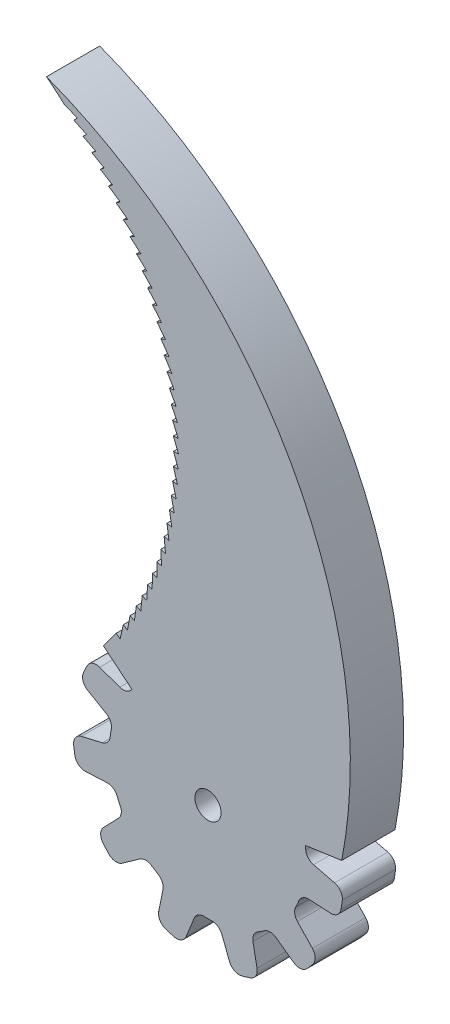
from build123d import *

# Parameters (mm, degrees)
ESBO_O1_R                = 1.6
RESSALTO_EXTRUS_O1_DEPTH = 6.5
RESSALTO_EXTRUS_O2_DEPTH = 6.5


with BuildPart() as part:
    # Esboço1 → Ressalto-extrusão1 (new body)
    with BuildSketch(Plane.XY):
        with BuildLine():
            Line((-1.729176319, 15.36379433), (-1.986939392, 12.728346928))
            ThreePointArc((-1.986939392, 12.728346928), (-2.28384954, 12.034303522), (-2.926191547, 11.637757646))
            ThreePointArc((-2.926191547, 11.637757646), (-3.379862838, 11.514188082), (-3.828344934, 11.372940476))
            ThreePointArc((-3.828344934, 11.372940476), (-4.589454473, 11.361285032), (-5.216203153, 11.793268448))
            Line((-5.216203153, 11.793268448), (-6.817074415, 13.864793941))
            ThreePointArc((-6.817074415, 13.864793941), (-7.572843667, 14.328475505), (-8.446001713, 14.174258833))
            ThreePointArc((-8.446001713, 14.174258833), (-8.906558945, 13.889484013), (-9.357523739, 13.589750104))
            ThreePointArc((-9.357523739, 13.589750104), (-9.86066415, 12.865881142), (-9.760970014, 11.989982959))
            Line((-9.760970014, 11.989982959), (-8.552983671, 9.633546283))
            ThreePointArc((-8.552983671, 9.633546283), (-8.427532188, 8.889158071), (-8.753515784, 8.208286144))
            ThreePointArc((-8.753515784, 8.208286144), (-9.06836161, 7.859059595), (-9.369284537, 7.497766819))
            ThreePointArc((-9.369284537, 7.497766819), (-10.003269217, 7.076474753), (-10.764071625, 7.101036409))
            Line((-10.764071625, 7.101036409), (-13.230761465, 7.9782182))
            ThreePointArc((-13.230761465, 7.9782182), (-14.117240198, 7.959692248), (-14.768411661, 7.357892048))
            ThreePointArc((-14.768411661, 7.357892048), (-15.001896169, 6.869328187), (-15.219223509, 6.373366001))
            ThreePointArc((-15.219223509, 6.373366001), (-15.25113905, 5.492390437), (-14.693724696, 4.809436716))
            Line((-14.693724696, 4.809436716), (-12.403516067, 3.480162761))
            ThreePointArc((-12.403516067, 3.480162761), (-11.895532912, 2.92176774), (-11.801660609, 2.172741789))
            ThreePointArc((-11.801660609, 2.172741789), (-11.877719645, 1.708735215), (-11.935542499, 1.242105174))
            ThreePointArc((-11.935542499, 1.242105174), (-12.241116663, 0.544933739), (-12.894423411, 0.154275483))
            Line((-12.894423411, 0.154275483), (-15.443775235, -0.441385447))
            ThreePointArc((-15.443775235, -0.441385447), (-16.179512714, -0.936237057), (-16.401955256, -1.794553473))
            ThreePointArc((-16.401955256, -1.794553473), (-16.334237357, -2.331790803), (-16.248927349, -2.866516774))
            ThreePointArc((-16.248927349, -2.866516774), (-15.799485061, -3.624895425), (-14.961325609, -3.898071703))
            Line((-14.961325609, -3.898071703), (-12.316019751, -3.778147849))
            ThreePointArc((-12.316019751, -3.778147849), (-11.586785986, -3.973263204), (-11.102861577, -4.552632733))
            ThreePointArc((-11.102861577, -4.552632733), (-10.915985617, -4.984100522), (-10.71235005, -5.407916088))
            ThreePointArc((-10.71235005, -5.407916088), (-10.592496061, -6.159619886), (-10.930886872, -6.841466818))
            Line((-10.930886872, -6.841466818), (-12.753499487, -8.720852334))
            ThreePointArc((-12.753499487, -8.720852334), (-13.104904263, -9.534917712), (-12.827993948, -10.377240947))
            ThreePointArc((-12.827993948, -10.377240947), (-12.480573597, -10.792582688), (-12.119711565, -11.196300728))
            ThreePointArc((-12.119711565, -11.196300728), (-11.331606199, -11.591302601), (-10.478811352, -11.367969899))
            Line((-10.478811352, -11.367969899), (-8.318274185, -9.836923211))
            ThreePointArc((-8.318274185, -9.836923211), (-7.599316379, -9.606811155), (-6.878982444, -9.83257853))
            ThreePointArc((-6.878982444, -9.83257853), (-6.488503284, -10.094519559), (-6.08806215, -10.340962202))
            ThreePointArc((-6.08806215, -10.340962202), (-5.580832802, -10.90853772), (-5.496870985, -11.665091745))
            Line((-5.496870985, -11.665091745), (-6.014077765, -14.231510224))
            ThreePointArc((-6.014077765, -14.231510224), (-5.869581302, -15.106329363), (-5.181235199, -15.665227742))
            ThreePointArc((-5.181235199, -15.665227742), (-4.664415904, -15.826805827), (-4.142572993, -15.971338309))
            ThreePointArc((-4.142572993, -15.971338309), (-3.266022434, -15.877553102), (-2.669348531, -15.228617974))
            Line((-2.669348531, -15.228617974), (-1.679535339, -12.772544959))
            ThreePointArc((-1.679535339, -12.772544959), (-1.199117515, -12.190264442), (-0.471074989, -11.990750116))
            ThreePointArc((-0.471074989, -11.990750116), (-0.000967004, -11.999999961), (0.469142466, -11.990825883))
            ThreePointArc((0.469142466, -11.990825883), (1.202705439, -12.194071903), (1.682362601, -12.785132464))
            Line((1.682362601, -12.785132464), (2.634771155, -15.223764172))
            ThreePointArc((2.634771155, -15.223764172), (3.229292249, -15.881588179), (4.110529116, -15.979615414))
            ThreePointArc((4.110529116, -15.979615414), (4.632660882, -15.836129942), (5.149803234, -15.675588826))
            ThreePointArc((5.149803234, -15.675588826), (5.836500377, -15.122792678), (5.987613588, -14.254287442))
            Line((5.987613588, -14.254287442), (5.49244411, -11.652973928))
            ThreePointArc((5.49244411, -11.652973928), (5.581792687, -10.903394902), (6.086395446, -10.341943264))
            ThreePointArc((6.086395446, -10.341943264), (6.486876293, -10.095565163), (6.877397664, -9.833687069))
            ThreePointArc((6.877397664, -9.833687069), (7.604393201, -9.608074416), (8.327457948, -9.845983961))
            Line((8.327457948, -9.845983961), (10.447098849, -11.382580562))
            ThreePointArc((10.447098849, -11.382580562), (11.302888328, -11.614554961), (12.097229481, -11.220588099))
            ThreePointArc((12.097229481, -11.220588099), (12.458900571, -10.817594694), (12.807153321, -10.402950649))
            ThreePointArc((12.807153321, -10.402950649), (13.085975557, -9.566652432), (12.743550699, -8.754321364))
            Line((12.743550699, -8.754321364), (10.920611362, -6.833666012))
            ThreePointArc((10.920611362, -6.833666012), (10.59052315, -6.154774519), (10.711478331, -5.409642498))
            ThreePointArc((10.711478331, -5.409642498), (10.915182201, -4.985859757), (11.102127697, -4.554422092))
            ThreePointArc((11.102127697, -4.554422092), (11.591739852, -3.97158119), (12.328644236, -3.780805119))
            Line((12.328644236, -3.780805119), (14.942546474, -3.927508049))
            ThreePointArc((14.942546474, -3.927508049), (15.787897226, -3.659982608), (16.24314496, -2.899103343))
            ThreePointArc((16.24314496, -2.899103343), (16.329527359, -2.364549564), (16.39832272, -1.827449144))
            ThreePointArc((16.39832272, -1.827449144), (16.180745959, -0.973167633), (15.453500505, -0.474920108))
            Line((15.453500505, -0.474920108), (12.881561668, 0.155282579))
            ThreePointArc((12.881561668, 0.155282579), (12.236837342, 0.547943285), (11.93574253, 1.240181539))
            ThreePointArc((11.93574253, 1.240181539), (11.877994883, 1.706820893), (11.80201063, 2.170839719))
            ThreePointArc((11.80201063, 2.170839719), (11.898791003, 2.925861002), (12.415573088, 3.484752635))
            Line((12.415573088, 3.484752635), (14.693841173, 4.77452052))
            ThreePointArc((14.693841173, 4.77452052), (15.260360306, 5.456608363), (15.231976684, 6.34282624))
            ThreePointArc((15.231976684, 6.34282624), (15.015644589, 6.839223346), (14.78314052, 7.328254551))
            ThreePointArc((14.78314052, 7.328254551), (14.138243847, 7.929291013), (13.25707309, 7.955264927))
            Line((13.25707309, 7.955264927), (10.752707161, 7.094930049))
            ThreePointArc((10.752707161, 7.094930049), (9.998042139, 7.076692968), (9.37049281, 7.496256699))
            ThreePointArc((9.37049281, 7.496256699), (9.069628116, 7.857597969), (8.754838577, 8.206875257))
            ThreePointArc((8.754838577, 8.206875257), (8.428060084, 8.894363), (8.56064521, 9.643926048))
            Line((8.56064521, 9.643926048), (9.779945121, 11.960672558))
            ThreePointArc((9.779945121, 11.960672558), (9.887766814, 12.840764734), (9.384763434, 13.570953308))
            ThreePointArc((9.384763434, 13.570953308), (8.934400758, 13.871591167), (8.474415657, 14.157289206))
            ThreePointArc((8.474415657, 14.157289206), (7.606949209, 14.314255788), (6.851618638, 13.859709557))
            Line((6.851618638, 13.859709557), (5.209944105, 11.781987358))
            ThreePointArc((5.209944105, 11.781987358), (4.5849392, 11.358642635), (3.830177831, 11.372323324))
            ThreePointArc((3.830177831, 11.372323324), (3.381718504, 11.51364321), (2.928067135, 11.637285889))
            ThreePointArc((2.928067135, 11.637285889), (2.281479638, 12.038967589), (1.987772964, 12.741221083))
            Line((1.987772964, 12.741221083), (1.760985595, 15.349395569))
            ThreePointArc((1.760985595, 15.349395569), (1.375877221, 16.148069029), (0.557954103, 16.490398589))
            ThreePointArc((0.557954103, 16.490398589), (0.016547813, 16.499826804), (-0.524876299, 16.491484568))
            ThreePointArc((-0.524876299, 16.491484568), (-1.339498055, 16.15454549), (-1.729176319, 15.36379433))
        make_face()
        Circle(ESBO_O1_R, mode=Mode.SUBTRACT)
    extrude(amount=RESSALTO_EXTRUS_O1_DEPTH)

    # Esboço6 → Ressalto-extrusão2 (add)
    with BuildSketch(Plane.XY.offset(6.5)):
        with BuildLine():
            Line((-4.114985122, 41.837254274), (-4.708205437, 41.747311742))
            Line((-4.708205437, 41.747311742), (-4.706221157, 41.734963389))
            Line((-4.706221157, 41.734963389), (-3.887744911, 40.217767328))
            Line((-3.887744911, 40.217767328), (-4.484080388, 40.151555562))
            Line((-4.484080388, 40.151555562), (-4.482590173, 40.139137895))
            Line((-4.482590173, 40.139137895), (-3.725274944, 38.590505951))
            Line((-3.725274944, 38.590505951), (-4.323776661, 38.548130309))
            Line((-4.323776661, 38.548130309), (-4.32278288, 38.535663088))
            Line((-4.32278288, 38.535663088), (-3.627833755, 36.958059537))
            Line((-3.627833755, 36.958059537), (-4.227549339, 36.939587451))
            Line((-4.227549339, 36.939587451), (-4.227053575, 36.927090515))
            Line((-4.227053575, 36.927090515), (-3.595576397, 35.323025732))
            Line((-3.595576397, 35.323025732), (-4.195551545, 35.328486595))
            Line((-4.195551545, 35.328486595), (-4.195554587, 35.31597983))
            Line((-4.195554587, 35.31597983), (-3.6285542, 33.6880063))
            Line((-3.6285542, 33.6880063), (-4.227834197, 33.717391422))
            Line((-4.227834197, 33.717391422), (-4.228336039, 33.704894729))
            Line((-4.228336039, 33.704894729), (-3.726714688, 32.05560298))
            Line((-3.726714688, 32.05560298), (-4.324345923, 32.108865603))
            Line((-4.324345923, 32.108865603), (-4.325345768, 32.096398867))
            Line((-4.325345768, 32.096398867), (-3.889901663, 30.42841335))
            Line((-3.889901663, 30.42841335), (-4.48493315, 30.505468719))
            Line((-4.48493315, 30.505468719), (-4.486429405, 30.493051778))
            Line((-4.486429405, 30.493051778), (-4.117855451, 28.809026691))
            Line((-4.117855451, 28.809026691), (-4.70934034, 28.90975219))
            Line((-4.70934034, 28.90975219), (-4.711330625, 28.897404804))
            Line((-4.711330625, 28.897404804), (-4.410213318, 27.200019868))
            Line((-4.410213318, 27.200019868), (-4.997210403, 27.324255217))
            Line((-4.997210403, 27.324255217), (-4.999691552, 27.311997033))
            Line((-4.999691552, 27.311997033), (-4.766510048, 25.603953228))
            Line((-4.766510048, 25.603953228), (-5.348085265, 25.751500737))
            Line((-5.348085265, 25.751500737), (-5.351053329, 25.73935126))
            Line((-5.351053329, 25.73935126), (-5.18617868, 24.023366527))
            Line((-5.18617868, 24.023366527), (-5.761406592, 24.193991409))
            Line((-5.761406592, 24.193991409), (-5.764856847, 24.181969973))
            Line((-5.764856847, 24.181969973), (-5.668551413, 22.460774889))
            Line((-5.668551413, 22.460774889), (-6.236516681, 22.654205635))
            Line((-6.236516681, 22.654205635), (-6.240443639, 22.642331369))
            Line((-6.240443639, 22.642331369), (-6.212860665, 20.918664803))
            Line((-6.212860665, 20.918664803), (-6.772659511, 21.134593615))
            Line((-6.772659511, 21.134593615), (-6.777056921, 21.122885414))
            Line((-6.777056921, 21.122885414), (-6.8182403, 19.399490166))
            Line((-6.8182403, 19.399490166), (-7.368981938, 19.637573445))
            Line((-7.368981938, 19.637573445), (-7.373842803, 19.62604994))
            Line((-7.373842803, 19.62604994), (-7.483727001, 17.905668379))
            Line((-7.483727001, 17.905668379), (-8.024535058, 18.165527274))
            Line((-8.024535058, 18.165527274), (-8.029851645, 18.154206801))
            Line((-8.029851645, 18.154206801), (-8.208261807, 16.439576501))
            Line((-8.208261807, 16.439576501), (-8.738275717, 16.720797508))
            Line((-8.738275717, 16.720797508), (-8.744039564, 16.709698082))
            Line((-8.744039564, 16.709698082), (-8.990691794, 15.003547464))
            Line((-8.990691794, 15.003547464), (-9.509068168, 15.305683087))
            Line((-9.509068168, 15.305683087), (-9.515270104, 15.29482237))
            Line((-9.515270104, 15.29482237), (-9.829771914, 13.599866363))
            Line((-9.829771914, 13.599866363), (-10.33568588, 13.922435827))
            Line((-10.33568588, 13.922435827), (-10.342316036, 13.9118311))
            Line((-10.342316036, 13.9118311), (-10.724166972, 12.23076682))
            Line((-10.724166972, 12.23076682), (-11.21681349, 12.573256832))
            Line((-11.21681349, 12.573256832), (-12.758134987, 10.463008652))
            Line((-12.758134987, 10.463008652), (-8.505508282, 6.975408775))
            ThreePointArc((-8.505508282, 6.975408775), (2.961370137, 10.59387963), (10.8897139, 1.553747045))
            Line((10.8897139, 1.553747045), (16.334407693, 2.330597288))
            ThreePointArc((16.334407693, 2.330597288), (10.105403869, 41.30916924), (-19.721278979, 67.164508153))
            ThreePointArc((-19.721278979, 67.164508153), (-18.619331766, 66.271987624), (-17.549389628, 65.341340335))
            Line((-17.549389628, 65.341340335), (-15.960172211, 64.673376823))
            Line((-15.960172211, 64.673376823), (-16.3830062, 64.24768748))
            ThreePointArc((-16.3830062, 64.24768748), (-16.378530334, 64.243320395), (-16.374055145, 64.238952618))
            Line((-16.374055145, 64.238952618), (-14.812742317, 63.508138341))
            Line((-14.812742317, 63.508138341), (-15.252217511, 63.099651433))
            ThreePointArc((-15.252217511, 63.099651433), (-15.247919377, 63.095109313), (-15.243621947, 63.090566529))
            Line((-15.243621947, 63.090566529), (-13.712698163, 62.298064402))
            Line((-13.712698163, 62.298064402), (-14.168115241, 61.907429937))
            ThreePointArc((-14.168115241, 61.907429937), (-14.164001679, 61.902720011), (-14.159888846, 61.898009448))
            Line((-14.159888846, 61.898009448), (-12.661790204, 61.045080547))
            Line((-12.661790204, 61.045080547), (-13.132424479, 60.672920127))
            ThreePointArc((-13.132424479, 60.672920127), (-13.128502035, 60.668049888), (-13.124580344, 60.663179042))
            Line((-13.124580344, 60.663179042), (-11.661690706, 59.751180599))
            Line((-11.661690706, 59.751180599), (-12.146793278, 59.398086427))
            ThreePointArc((-12.146793278, 59.398086427), (-12.143068193, 59.393063626), (-12.139343884, 59.388040248))
            Line((-12.139343884, 59.388040248), (-10.713991088, 58.418423489))
            Line((-10.713991088, 58.418423489), (-11.212790033, 58.08495743))
            ThreePointArc((-11.212790033, 58.08495743), (-11.209268234, 58.079790059), (-11.205747235, 58.074622142))
            Line((-11.205747235, 58.074622142), (-9.820199386, 57.048929979))
            Line((-9.820199386, 57.048929979), (-10.331900985, 56.735622664))
            ThreePointArc((-10.331900985, 56.735622664), (-10.328588077, 56.730318945), (-10.325275989, 56.725014714))
            Line((-10.325275989, 56.725014714), (-8.981737855, 55.644879289))
            Line((-8.981737855, 55.644879289), (-9.505527858, 55.352229271))
            ThreePointArc((-9.505527858, 55.352229271), (-9.502429111, 55.346797645), (-9.499331206, 55.341365538))
            Line((-9.499331206, 55.341365538), (-8.199940704, 54.208505628))
            Line((-8.199940704, 54.208505628), (-8.734985625, 53.936978589))
            ThreePointArc((-8.734985625, 53.936978589), (-8.732105972, 53.931427698), (-8.729227178, 53.925876361))
            Line((-8.729227178, 53.925876361), (-7.476051976, 52.742094639))
            Line((-7.476051976, 52.742094639), (-8.021500419, 52.49212265))
            ThreePointArc((-8.021500419, 52.49212265), (-8.018844442, 52.486461327), (-8.01618934, 52.480799592))
            Line((-8.01618934, 52.480799592), (-6.811223565, 51.247979762))
            Line((-6.811223565, 51.247979762), (-7.366207581, 51.019960593))
            ThreePointArc((-7.366207581, 51.019960593), (-7.363779505, 51.014197847), (-7.361352321, 51.008434724))
            Line((-7.361352321, 51.008434724), (-6.206513386, 49.728538523))
            Line((-6.206513386, 49.728538523), (-6.770149851, 49.522835011))
            ThreePointArc((-6.770149851, 49.522835011), (-6.767953541, 49.516980012), (-6.765758137, 49.511124672))
            Line((-6.765758137, 49.511124672), (-5.66288369, 48.186188746))
            Line((-5.66288369, 48.186188746), (-6.234275713, 48.003128219))
            ThreePointArc((-6.234275713, 48.003128219), (-6.232314662, 47.997190284), (-6.230354531, 47.991252044))
            Line((-6.230354531, 47.991252044), (-5.181199533, 46.623384711))
            Line((-5.181199533, 46.623384711), (-5.759437879, 46.463258466))
            ThreePointArc((-5.759437879, 46.463258466), (-5.75771521, 46.457247043), (-5.755993472, 46.451235353))
            Line((-5.755993472, 46.451235353), (-4.762227399, 45.042613244))
            Line((-4.762227399, 45.042613244), (-5.346391942, 44.905676083))
            ThreePointArc((-5.346391942, 44.905676083), (-5.344910395, 44.899600738), (-5.343429789, 44.893525164))
            Line((-5.343429789, 44.893525164), (-4.406633982, 43.446389763))
            Line((-4.406633982, 43.446389763), (-4.995795165, 43.332859589))
            ThreePointArc((-4.995795165, 43.332859589), (-4.994557097, 43.326729989), (-4.993319979, 43.320600199))
            Line((-4.993319979, 43.320600199), (-4.114985122, 41.837254274))
        make_face()
    extrude(amount=-RESSALTO_EXTRUS_O2_DEPTH)


solid = part.part
